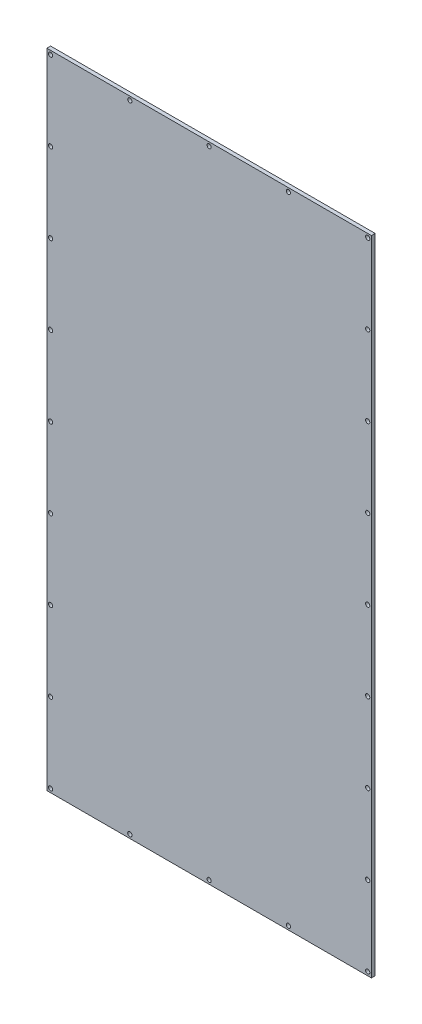
from build123d import *

# Parameters (mm, degrees)
SKETCH1_W            = 260
SKETCH1_H            = 515
BOSS_EXTRUDE1_DEPTH  = 2.9972
M3_CLEARANCE_HOLE1_D = 3.4
M3_CLEARANCE_HOLE2_D = 3.4
LPATTERN1_COUNT      = 5
LPATTERN1_PITCH      = 63.625
LPATTERN1_COUNT_DIR2 = 5
LPATTERN1_PITCH_DIR2 = 63.625
LPATTERN2_COUNT      = 3
LPATTERN2_PITCH      = 63.5
LPATTERN2_COL_COUNT  = 3
LPATTERN2_COL_PITCH  = 63.5
MIRROR1_COPY_1_D     = 3.4
MIRROR1_COPY_2_D     = 3.4
MIRROR1_COPY_3_D     = 3.4
MIRROR1_COPY_4_D     = 3.4
MIRROR1_COPY_5_D     = 3.4
MIRROR1_COPY_6_D     = 3.4
MIRROR1_COPY_7_D     = 3.4
MIRROR1_COPY_8_D     = 3.4
MIRROR1_COPY_9_D     = 3.4
MIRROR1_COPY_10_D    = 3.4
MIRROR1_COPY_11_D    = 3.4
MIRROR1_COPY_12_D    = 3.4
MIRROR1_COPY_13_D    = 3.4
MIRROR1_COPY_14_D    = 3.4
MIRROR1_COPY_15_D    = 3.4
MIRROR1_COPY_16_D    = 3.4
MIRROR1_COPY_17_D    = 3.4
MIRROR1_COPY_18_D    = 3.4
MIRROR1_COPY_19_D    = 3.4
MIRROR1_COPY_20_D    = 3.4
MIRROR1_COPY_21_D    = 3.4
MIRROR1_COPY_22_D    = 3.4
MIRROR2_COPY_1_D     = 3.4
MIRROR2_COPY_2_D     = 3.4
MIRROR2_COPY_3_D     = 3.4
MIRROR2_COPY_4_D     = 3.4


with BuildPart() as part:
    # Sketch1 → Boss-Extrude1 (new body)
    with BuildSketch(Plane.XY):
        with Locations((130, 257.5)):
            Rectangle(SKETCH1_W, SKETCH1_H)
    extrude(amount=BOSS_EXTRUDE1_DEPTH)

    # M3 Clearance Hole1 (through all)
    with Locations(Plane.XY.offset(2.9972)):
        with Locations((257, 257.5)):
            m3_clearance_hole1 = Hole(M3_CLEARANCE_HOLE1_D / 2)

    # M3 Clearance Hole2 (through all)
    with Locations(Plane.XY.offset(2.9972)):
        with Locations((130, 512)):
            m3_clearance_hole2 = Hole(M3_CLEARANCE_HOLE2_D / 2)

    # LPattern1: M3 Clearance Hole1 5 × 5, 2 skipped
    with Locations(*[Vector(0, -1, 0) * (i * LPATTERN1_PITCH) + Vector(0, 1, 0) * (j * LPATTERN1_PITCH_DIR2) for i in range(LPATTERN1_COUNT) for j in range(LPATTERN1_COUNT_DIR2) if (i, j) not in ((0, 0), (0, 4), (4, 0))]):
        add(m3_clearance_hole1, mode=Mode.SUBTRACT)

    # LPattern2: M3 Clearance Hole2 ×3
    with Locations(*[(i * LPATTERN2_PITCH, 0, 0) for i in range(1, LPATTERN2_COUNT)]):
        add(m3_clearance_hole2, mode=Mode.SUBTRACT)

    # LPattern2 col: M3 Clearance Hole2 ×3
    with Locations(*[(-i * LPATTERN2_COL_PITCH, 0, 0) for i in range(1, LPATTERN2_COL_COUNT)]):
        add(m3_clearance_hole2, mode=Mode.SUBTRACT)

    # Mirror1: M3 Clearance Hole1 across plane
    add(m3_clearance_hole1.mirror(Plane.ZY.offset(-130)), mode=Mode.SUBTRACT)

    # Mirror1 copy 1 (through all)
    with Locations(Plane(origin=(260, 63.625, 2.9972), x_dir=(-1, 0, 0), z_dir=(0, 0, 1))):
        with Locations((257, -257.5)):
            Hole(MIRROR1_COPY_1_D / 2)

    # Mirror1 copy 2 (through all)
    with Locations(Plane(origin=(260, 127.25, 2.9972), x_dir=(-1, 0, 0), z_dir=(0, 0, 1))):
        with Locations((257, -257.5)):
            Hole(MIRROR1_COPY_2_D / 2)

    # Mirror1 copy 3 (through all)
    with Locations(Plane(origin=(260, 190.875, 2.9972), x_dir=(-1, 0, 0), z_dir=(0, 0, 1))):
        with Locations((257, -257.5)):
            Hole(MIRROR1_COPY_3_D / 2)

    # Mirror1 copy 4 (through all)
    with Locations(Plane(origin=(260, -63.625, 2.9972), x_dir=(-1, 0, 0), z_dir=(0, 0, 1))):
        with Locations((257, -257.5)):
            Hole(MIRROR1_COPY_4_D / 2)

    # Mirror1 copy 5 (through all)
    with Locations(Plane(origin=(260, 0, 2.9972), x_dir=(-1, 0, 0), z_dir=(0, 0, 1))):
        with Locations((257, -257.5)):
            Hole(MIRROR1_COPY_5_D / 2)

    # Mirror1 copy 6 (through all)
    with Locations(Plane(origin=(260, 63.625, 2.9972), x_dir=(-1, 0, 0), z_dir=(0, 0, 1))):
        with Locations((257, -257.5)):
            Hole(MIRROR1_COPY_6_D / 2)

    # Mirror1 copy 7 (through all)
    with Locations(Plane(origin=(260, 127.25, 2.9972), x_dir=(-1, 0, 0), z_dir=(0, 0, 1))):
        with Locations((257, -257.5)):
            Hole(MIRROR1_COPY_7_D / 2)

    # Mirror1 copy 8 (through all)
    with Locations(Plane(origin=(260, 190.875, 2.9972), x_dir=(-1, 0, 0), z_dir=(0, 0, 1))):
        with Locations((257, -257.5)):
            Hole(MIRROR1_COPY_8_D / 2)

    # Mirror1 copy 9 (through all)
    with Locations(Plane(origin=(260, -127.25, 2.9972), x_dir=(-1, 0, 0), z_dir=(0, 0, 1))):
        with Locations((257, -257.5)):
            Hole(MIRROR1_COPY_9_D / 2)

    # Mirror1 copy 10 (through all)
    with Locations(Plane(origin=(260, -63.625, 2.9972), x_dir=(-1, 0, 0), z_dir=(0, 0, 1))):
        with Locations((257, -257.5)):
            Hole(MIRROR1_COPY_10_D / 2)

    # Mirror1 copy 11 (through all)
    with Locations(Plane(origin=(260, 0, 2.9972), x_dir=(-1, 0, 0), z_dir=(0, 0, 1))):
        with Locations((257, -257.5)):
            Hole(MIRROR1_COPY_11_D / 2)

    # Mirror1 copy 12 (through all)
    with Locations(Plane(origin=(260, 63.625, 2.9972), x_dir=(-1, 0, 0), z_dir=(0, 0, 1))):
        with Locations((257, -257.5)):
            Hole(MIRROR1_COPY_12_D / 2)

    # Mirror1 copy 13 (through all)
    with Locations(Plane(origin=(260, 127.25, 2.9972), x_dir=(-1, 0, 0), z_dir=(0, 0, 1))):
        with Locations((257, -257.5)):
            Hole(MIRROR1_COPY_13_D / 2)

    # Mirror1 copy 14 (through all)
    with Locations(Plane(origin=(260, -190.875, 2.9972), x_dir=(-1, 0, 0), z_dir=(0, 0, 1))):
        with Locations((257, -257.5)):
            Hole(MIRROR1_COPY_14_D / 2)

    # Mirror1 copy 15 (through all)
    with Locations(Plane(origin=(260, -127.25, 2.9972), x_dir=(-1, 0, 0), z_dir=(0, 0, 1))):
        with Locations((257, -257.5)):
            Hole(MIRROR1_COPY_15_D / 2)

    # Mirror1 copy 16 (through all)
    with Locations(Plane(origin=(260, -63.625, 2.9972), x_dir=(-1, 0, 0), z_dir=(0, 0, 1))):
        with Locations((257, -257.5)):
            Hole(MIRROR1_COPY_16_D / 2)

    # Mirror1 copy 17 (through all)
    with Locations(Plane(origin=(260, 0, 2.9972), x_dir=(-1, 0, 0), z_dir=(0, 0, 1))):
        with Locations((257, -257.5)):
            Hole(MIRROR1_COPY_17_D / 2)

    # Mirror1 copy 18 (through all)
    with Locations(Plane(origin=(260, 63.625, 2.9972), x_dir=(-1, 0, 0), z_dir=(0, 0, 1))):
        with Locations((257, -257.5)):
            Hole(MIRROR1_COPY_18_D / 2)

    # Mirror1 copy 19 (through all)
    with Locations(Plane(origin=(260, -190.875, 2.9972), x_dir=(-1, 0, 0), z_dir=(0, 0, 1))):
        with Locations((257, -257.5)):
            Hole(MIRROR1_COPY_19_D / 2)

    # Mirror1 copy 20 (through all)
    with Locations(Plane(origin=(260, -127.25, 2.9972), x_dir=(-1, 0, 0), z_dir=(0, 0, 1))):
        with Locations((257, -257.5)):
            Hole(MIRROR1_COPY_20_D / 2)

    # Mirror1 copy 21 (through all)
    with Locations(Plane(origin=(260, -63.625, 2.9972), x_dir=(-1, 0, 0), z_dir=(0, 0, 1))):
        with Locations((257, -257.5)):
            Hole(MIRROR1_COPY_21_D / 2)

    # Mirror1 copy 22 (through all)
    with Locations(Plane(origin=(260, 0, 2.9972), x_dir=(-1, 0, 0), z_dir=(0, 0, 1))):
        with Locations((257, -257.5)):
            Hole(MIRROR1_COPY_22_D / 2)

    # Mirror2: M3 Clearance Hole2 across plane
    add(m3_clearance_hole2.mirror(Plane.ZX.offset(257.5)), mode=Mode.SUBTRACT)

    # Mirror2 copy 1 (through all)
    with Locations(Plane(origin=(63.5, 515, 2.9972), x_dir=(1, 0, 0), z_dir=(0, 0, 1))):
        with Locations((130, -512)):
            Hole(MIRROR2_COPY_1_D / 2)

    # Mirror2 copy 2 (through all)
    with Locations(Plane(origin=(127, 515, 2.9972), x_dir=(1, 0, 0), z_dir=(0, 0, 1))):
        with Locations((130, -512)):
            Hole(MIRROR2_COPY_2_D / 2)

    # Mirror2 copy 3 (through all)
    with Locations(Plane(origin=(-63.5, 515, 2.9972), x_dir=(1, 0, 0), z_dir=(0, 0, 1))):
        with Locations((130, -512)):
            Hole(MIRROR2_COPY_3_D / 2)

    # Mirror2 copy 4 (through all)
    with Locations(Plane(origin=(-127, 515, 2.9972), x_dir=(1, 0, 0), z_dir=(0, 0, 1))):
        with Locations((130, -512)):
            Hole(MIRROR2_COPY_4_D / 2)


solid = part.part
